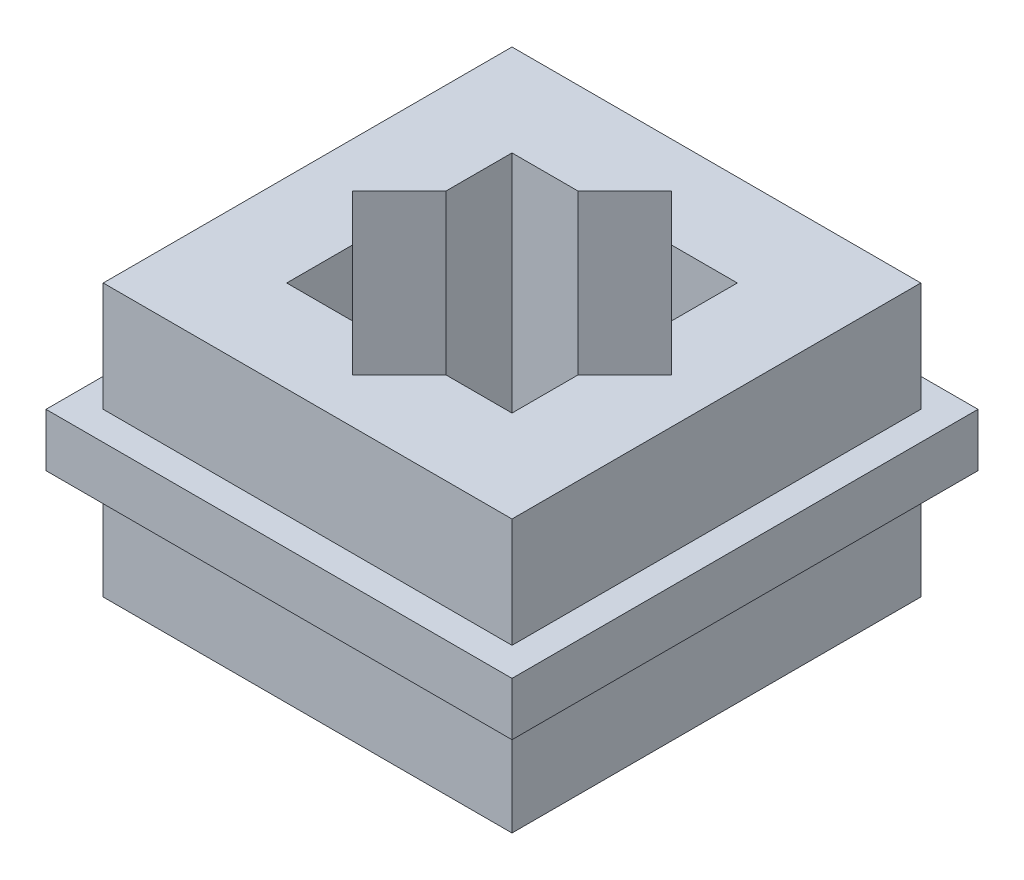
from build123d import *

# Parameters (mm, degrees)
SKETCH1_W           = 25.4
SKETCH1_H           = 25.4
BOSS_EXTRUDE1_DEPTH = 8.45
SKETCH2_W           = 28.956
SKETCH2_H           = 28.956
BOSS_EXTRUDE2_DEPTH = 1.651
CUT_EXTRUDE1_DEPTH  = 27.54872818
CIRPATTERN1_COUNT   = 2
CIRPATTERN1_ANGLE   = 45
SKETCH4_W           = 14
SKETCH4_H           = 14
CUT_EXTRUDE2_DEPTH  = 27.54872818


with BuildPart() as part:
    # Sketch1 → Boss-Extrude1 (new, symmetric)
    with BuildSketch(Plane(origin=(0, 0, 0), x_dir=(1, 0, 0), z_dir=(0, 1, 0))):
        Rectangle(SKETCH1_W, SKETCH1_H)
    extrude(amount=BOSS_EXTRUDE1_DEPTH, both=True)

    # Sketch2 → Boss-Extrude2 (add, symmetric)
    with BuildSketch(Plane(origin=(0, 0, 0), x_dir=(1, 0, 0), z_dir=(0, 1, 0))):
        Rectangle(SKETCH2_W, SKETCH2_H)
    extrude(amount=BOSS_EXTRUDE2_DEPTH, both=True)

    # Sketch3 → Cut-Extrude1 (cut, through all)
    with BuildSketch(Plane(origin=(0, 8.45, 0), x_dir=(1, 0, 0), z_dir=(0, 1, 0))):
        Polygon((-5.727922061, 7), (-7, 5.727922061), (-7, -5.727922061), (-5.727922061, -7), (5.727922061, -7), (7, -5.727922061), (7, 5.727922061), (5.727922061, 7), align=None)
    cut_extrude1 = extrude(amount=-CUT_EXTRUDE1_DEPTH, mode=Mode.SUBTRACT)

    # CirPattern1: Cut-Extrude1 ×2 about axis
    cirpattern1_axis = Axis((0, 50, 0), (0, -1, 0))
    for i in range(1, CIRPATTERN1_COUNT):
        add(cut_extrude1.rotate(cirpattern1_axis, i * CIRPATTERN1_ANGLE / (CIRPATTERN1_COUNT - 1)), mode=Mode.SUBTRACT)

    # Sketch4 → Cut-Extrude2 (cut, through all)
    with BuildSketch(Plane(origin=(0, 8.45, 0), x_dir=(1, 0, 0), z_dir=(0, 1, 0))):
        Rectangle(SKETCH4_W, SKETCH4_H)
        Polygon((0, -9.899494937), (-9.899494937, 0), (0, 9.899494937), (9.899494937, 0), align=None)
    extrude(amount=-CUT_EXTRUDE2_DEPTH, mode=Mode.SUBTRACT)


solid = part.part
